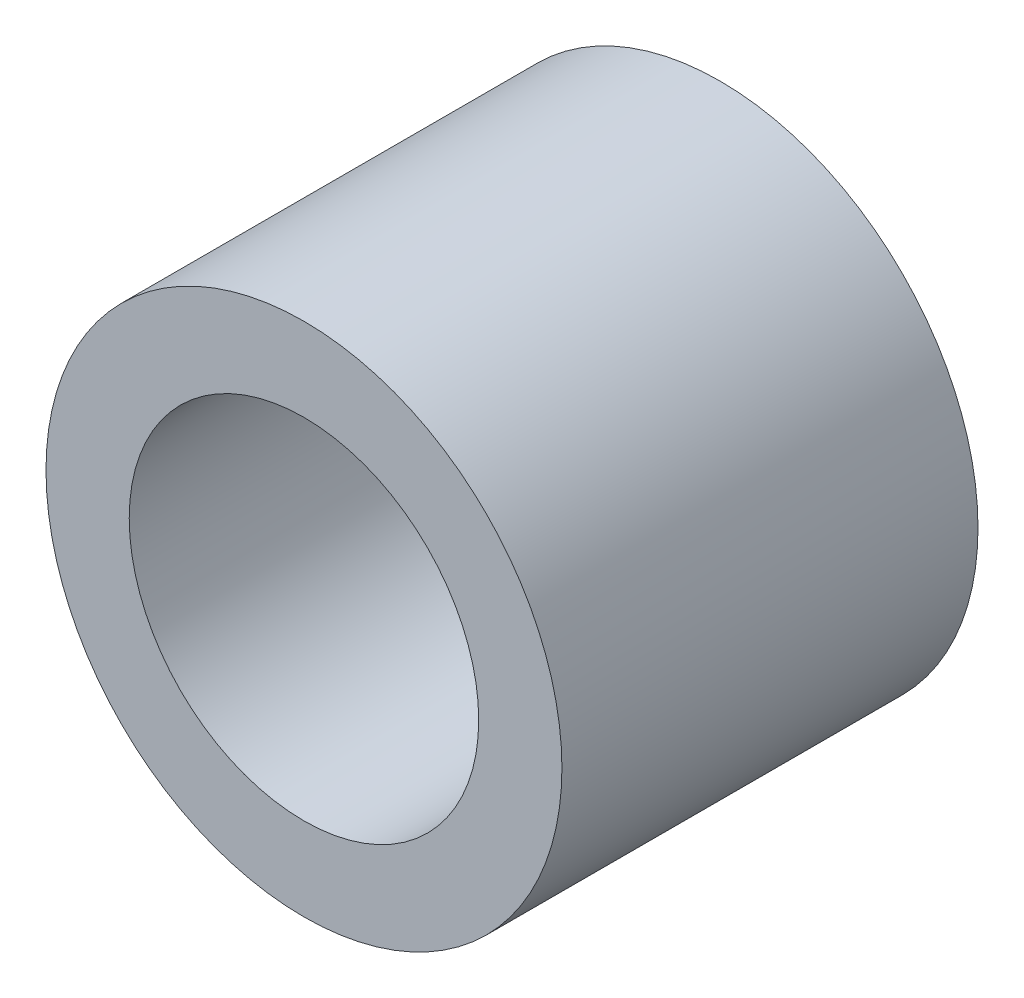
from build123d import *

# Parameters (mm, degrees)
SKETCH3_R           = 3.1
SKETCH3_R_2         = 2.1
BOSS_EXTRUDE1_DEPTH = 5


with BuildPart() as part:
    # Sketch3 → Boss-Extrude1 (new body)
    with BuildSketch(Plane.XY):
        Circle(SKETCH3_R)
        Circle(SKETCH3_R_2, mode=Mode.SUBTRACT)
    extrude(amount=BOSS_EXTRUDE1_DEPTH)


solid = part.part
